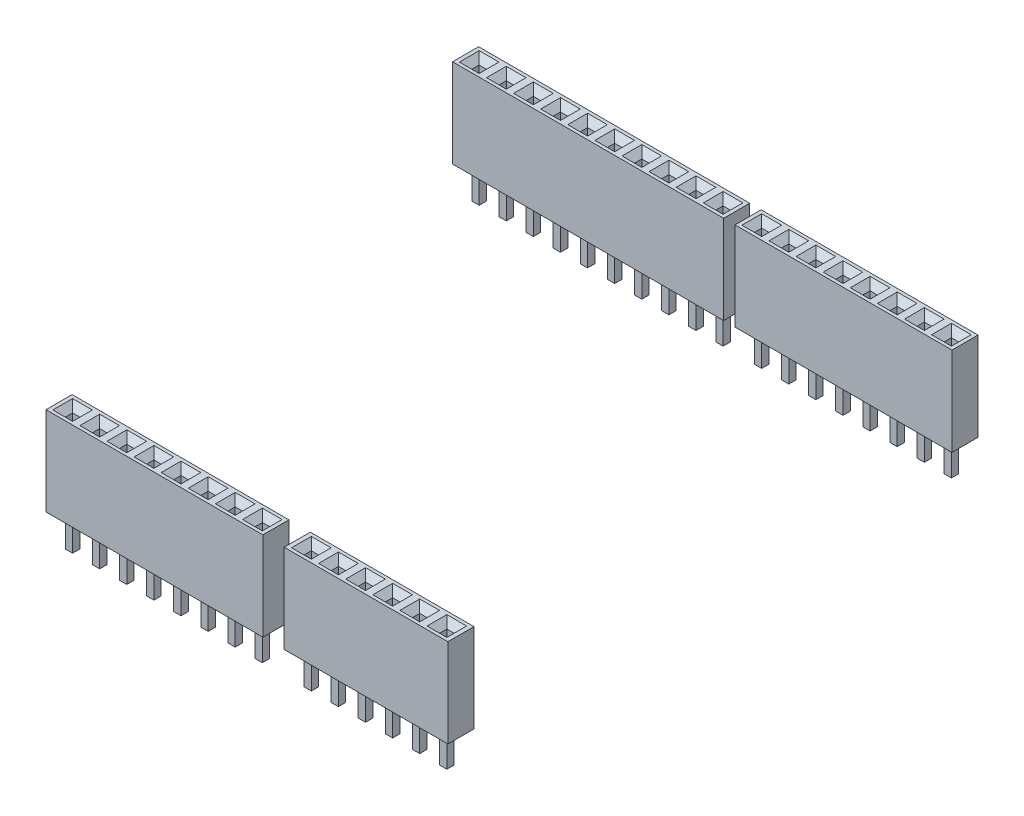
from build123d import *

# Parameters (mm, degrees)
ESQUISSE1_W             = 20.8
ESQUISSE1_H             = 2.5
BOSS_EXTRU_1_DEPTH      = 8.5
ESQUISSE1_W_2           = 15.7
BOSS_EXTRU_1_2_DEPTH    = 8.5
BOSS_EXTRU_1_3_DEPTH    = 8.5
ESQUISSE1_W_3           = 26
BOSS_EXTRU_1_4_DEPTH    = 8.5
ESQUISSE2_W             = 0.7
ESQUISSE2_H             = 0.7
BOSS_EXTRU_2_DEPTH      = 3.2
CHANFREIN1_SIZE         = 0.15
CHANFREIN2_SIZE         = 0.15
CHANFREIN3_SIZE         = 0.15
CHANFREIN4_SIZE         = 0.15
ESQUISSE3_W             = 0.7
ESQUISSE3_H             = 0.7
ENL_V_MAT_EXTRU_1_DEPTH = 7
CHANFREIN5_SIZE         = 0.6
CHANFREIN6_SIZE         = 0.6
CHANFREIN7_SIZE         = 0.6
CHANFREIN8_SIZE         = 0.6


with BuildPart() as part:
    # Esquisse1 → Boss.-Extru.1 (new body)
    with BuildSketch(Plane(origin=(0, 0, 0), x_dir=(1, 0, 0), z_dir=(0, 1, 0))):
        with Locations((10.4, 1.25)):
            Rectangle(ESQUISSE1_W, ESQUISSE1_H)
    extrude(amount=BOSS_EXTRU_1_DEPTH)



with BuildPart() as body_2:
    # Esquisse1 → Boss.-Extru.1 2 (new body)
    with BuildSketch(Plane(origin=(0, 0, 0), x_dir=(1, 0, 0), z_dir=(0, 1, 0))):
        with Locations((30.7, 1.25)):
            Rectangle(ESQUISSE1_W_2, ESQUISSE1_H)
    extrude(amount=BOSS_EXTRU_1_2_DEPTH)


with BuildPart() as body_3:
    # Esquisse1 → Boss.-Extru.1 3 (new body)
    with BuildSketch(Plane(origin=(0, 0, 0), x_dir=(1, 0, 0), z_dir=(0, 1, 0))):
        with Locations((28.1, 49.65)):
            Rectangle(ESQUISSE1_W, ESQUISSE1_H)
    extrude(amount=BOSS_EXTRU_1_3_DEPTH)


with BuildPart() as body_4:
    # Esquisse1 → Boss.-Extru.1 4 (new body)
    with BuildSketch(Plane(origin=(0, 0, 0), x_dir=(1, 0, 0), z_dir=(0, 1, 0))):
        with Locations((3.6, 49.65)):
            Rectangle(ESQUISSE1_W_3, ESQUISSE1_H)
    extrude(amount=BOSS_EXTRU_1_4_DEPTH)


with BuildPart() as part_1:
    add(part.part)

    add(body_2.part)  # Boss.-Extru.2 merges body 2

    add(body_3.part)  # Boss.-Extru.2 merges body 3

    add(body_4.part)  # Boss.-Extru.2 merges body 4
    # Esquisse2 → Boss.-Extru.2 (add)
    with BuildSketch(Plane.XZ):
        with Locations((1.3, -1.25)):
            Rectangle(ESQUISSE2_W, ESQUISSE2_H)
        with Locations((3.9, -1.25)):
            Rectangle(ESQUISSE2_W, ESQUISSE2_H)
        with Locations((6.5, -1.25)):
            Rectangle(ESQUISSE2_W, ESQUISSE2_H)
        with Locations((9.1, -1.25)):
            Rectangle(ESQUISSE2_W, ESQUISSE2_H)
        with Locations((11.7, -1.25)):
            Rectangle(ESQUISSE2_W, ESQUISSE2_H)
        with Locations((14.3, -1.25)):
            Rectangle(ESQUISSE2_W, ESQUISSE2_H)
        with Locations((16.9, -1.25)):
            Rectangle(ESQUISSE2_W, ESQUISSE2_H)
        with Locations((19.5, -1.25)):
            Rectangle(ESQUISSE2_W, ESQUISSE2_H)
        with Locations((24.2, -1.25)):
            Rectangle(ESQUISSE2_W, ESQUISSE2_H)
        with Locations((26.8, -1.25)):
            Rectangle(ESQUISSE2_W, ESQUISSE2_H)
        with Locations((29.4, -1.25)):
            Rectangle(ESQUISSE2_W, ESQUISSE2_H)
        with Locations((32, -1.25)):
            Rectangle(ESQUISSE2_W, ESQUISSE2_H)
        with Locations((34.6, -1.25)):
            Rectangle(ESQUISSE2_W, ESQUISSE2_H)
        with Locations((37.2, -1.25)):
            Rectangle(ESQUISSE2_W, ESQUISSE2_H)
        with Locations((-8.1, -49.65)):
            Rectangle(ESQUISSE2_W, ESQUISSE2_H)
        with Locations((-5.5, -49.65)):
            Rectangle(ESQUISSE2_W, ESQUISSE2_H)
        with Locations((-2.9, -49.65)):
            Rectangle(ESQUISSE2_W, ESQUISSE2_H)
        with Locations((-0.3, -49.65)):
            Rectangle(ESQUISSE2_W, ESQUISSE2_H)
        with Locations((2.3, -49.65)):
            Rectangle(ESQUISSE2_W, ESQUISSE2_H)
        with Locations((4.9, -49.65)):
            Rectangle(ESQUISSE2_W, ESQUISSE2_H)
        with Locations((7.5, -49.65)):
            Rectangle(ESQUISSE2_W, ESQUISSE2_H)
        with Locations((10.1, -49.65)):
            Rectangle(ESQUISSE2_W, ESQUISSE2_H)
        with Locations((12.7, -49.65)):
            Rectangle(ESQUISSE2_W, ESQUISSE2_H)
        with Locations((15.3, -49.65)):
            Rectangle(ESQUISSE2_W, ESQUISSE2_H)
        with Locations((19, -49.65)):
            Rectangle(ESQUISSE2_W, ESQUISSE2_H)
        with Locations((21.6, -49.65)):
            Rectangle(ESQUISSE2_W, ESQUISSE2_H)
        with Locations((24.2, -49.65)):
            Rectangle(ESQUISSE2_W, ESQUISSE2_H)
        with Locations((26.8, -49.65)):
            Rectangle(ESQUISSE2_W, ESQUISSE2_H)
        with Locations((29.4, -49.65)):
            Rectangle(ESQUISSE2_W, ESQUISSE2_H)
        with Locations((32, -49.65)):
            Rectangle(ESQUISSE2_W, ESQUISSE2_H)
        with Locations((34.6, -49.65)):
            Rectangle(ESQUISSE2_W, ESQUISSE2_H)
        with Locations((37.2, -49.65)):
            Rectangle(ESQUISSE2_W, ESQUISSE2_H)
    extrude(amount=BOSS_EXTRU_2_DEPTH)

    # Chanfrein1
    chanfrein1_edges = [part_1.edges().sort_by_distance(p)[0] for p in [
        (0.95, -3.2, -1.25),
        (1.3, -3.2, -1.6),
        (1.65, -3.2, -1.25),
        (1.3, -3.2, -0.9),
        (3.55, -3.2, -1.25),
        (3.9, -3.2, -1.6),
        (4.25, -3.2, -1.25),
        (3.9, -3.2, -0.9),
        (6.15, -3.2, -1.25),
        (6.5, -3.2, -1.6),
        (6.85, -3.2, -1.25),
        (6.5, -3.2, -0.9),
        (8.75, -3.2, -1.25),
        (9.1, -3.2, -1.6),
        (9.45, -3.2, -1.25),
        (9.1, -3.2, -0.9),
        (11.35, -3.2, -1.25),
        (11.7, -3.2, -1.6),
        (12.05, -3.2, -1.25),
        (11.7, -3.2, -0.9),
        (13.95, -3.2, -1.25),
        (14.3, -3.2, -1.6),
        (14.65, -3.2, -1.25),
        (14.3, -3.2, -0.9),
        (16.55, -3.2, -1.25),
        (16.9, -3.2, -1.6),
        (17.25, -3.2, -1.25),
        (16.9, -3.2, -0.9),
        (19.15, -3.2, -1.25),
        (19.5, -3.2, -1.6),
        (19.85, -3.2, -1.25),
        (19.5, -3.2, -0.9),
    ]]
    chamfer(chanfrein1_edges, length=CHANFREIN1_SIZE)

    # Chanfrein2
    chanfrein2_edges = [part_1.edges().sort_by_distance(p)[0] for p in [
        (26.45, -3.2, -1.25),
        (26.8, -3.2, -1.6),
        (27.15, -3.2, -1.25),
        (26.8, -3.2, -0.9),
        (23.85, -3.2, -1.25),
        (24.2, -3.2, -1.6),
        (24.55, -3.2, -1.25),
        (24.2, -3.2, -0.9),
        (29.05, -3.2, -1.25),
        (29.4, -3.2, -1.6),
        (29.75, -3.2, -1.25),
        (29.4, -3.2, -0.9),
        (31.65, -3.2, -1.25),
        (32, -3.2, -1.6),
        (32.35, -3.2, -1.25),
        (32, -3.2, -0.9),
        (34.25, -3.2, -1.25),
        (34.6, -3.2, -1.6),
        (34.95, -3.2, -1.25),
        (34.6, -3.2, -0.9),
        (36.85, -3.2, -1.25),
        (37.2, -3.2, -1.6),
        (37.55, -3.2, -1.25),
        (37.2, -3.2, -0.9),
    ]]
    chamfer(chanfrein2_edges, length=CHANFREIN2_SIZE)

    # Chanfrein3
    chanfrein3_edges = [part_1.edges().sort_by_distance(p)[0] for p in [
        (12.35, -3.2, -49.65),
        (12.7, -3.2, -50),
        (13.05, -3.2, -49.65),
        (12.7, -3.2, -49.3),
        (14.95, -3.2, -49.65),
        (15.3, -3.2, -50),
        (15.65, -3.2, -49.65),
        (15.3, -3.2, -49.3),
        (-8.45, -3.2, -49.65),
        (-8.1, -3.2, -50),
        (-7.75, -3.2, -49.65),
        (-8.1, -3.2, -49.3),
        (-5.85, -3.2, -49.65),
        (-5.5, -3.2, -50),
        (-5.15, -3.2, -49.65),
        (-5.5, -3.2, -49.3),
        (-3.25, -3.2, -49.65),
        (-2.9, -3.2, -50),
        (-2.55, -3.2, -49.65),
        (-2.9, -3.2, -49.3),
        (-0.65, -3.2, -49.65),
        (-0.3, -3.2, -50),
        (0.05, -3.2, -49.65),
        (-0.3, -3.2, -49.3),
        (1.95, -3.2, -49.65),
        (2.3, -3.2, -50),
        (2.65, -3.2, -49.65),
        (2.3, -3.2, -49.3),
        (4.55, -3.2, -49.65),
        (4.9, -3.2, -50),
        (5.25, -3.2, -49.65),
        (4.9, -3.2, -49.3),
        (7.15, -3.2, -49.65),
        (7.5, -3.2, -50),
        (7.85, -3.2, -49.65),
        (7.5, -3.2, -49.3),
        (9.75, -3.2, -49.65),
        (10.1, -3.2, -50),
        (10.45, -3.2, -49.65),
        (10.1, -3.2, -49.3),
    ]]
    chamfer(chanfrein3_edges, length=CHANFREIN3_SIZE)

    # Chanfrein4
    chanfrein4_edges = [part_1.edges().sort_by_distance(p)[0] for p in [
        (18.65, -3.2, -49.65),
        (19, -3.2, -50),
        (19.35, -3.2, -49.65),
        (19, -3.2, -49.3),
        (21.25, -3.2, -49.65),
        (21.6, -3.2, -50),
        (21.95, -3.2, -49.65),
        (21.6, -3.2, -49.3),
        (23.85, -3.2, -49.65),
        (24.2, -3.2, -50),
        (24.55, -3.2, -49.65),
        (24.2, -3.2, -49.3),
        (26.45, -3.2, -49.65),
        (26.8, -3.2, -50),
        (27.15, -3.2, -49.65),
        (26.8, -3.2, -49.3),
        (29.05, -3.2, -49.65),
        (29.4, -3.2, -50),
        (29.75, -3.2, -49.65),
        (29.4, -3.2, -49.3),
        (31.65, -3.2, -49.65),
        (32, -3.2, -50),
        (32.35, -3.2, -49.65),
        (32, -3.2, -49.3),
        (34.25, -3.2, -49.65),
        (34.6, -3.2, -50),
        (34.95, -3.2, -49.65),
        (34.6, -3.2, -49.3),
        (36.85, -3.2, -49.65),
        (37.2, -3.2, -50),
        (37.55, -3.2, -49.65),
        (37.2, -3.2, -49.3),
    ]]
    chamfer(chanfrein4_edges, length=CHANFREIN4_SIZE)

    # Esquisse3 → Enlèv. mat.-Extru.1 (cut)
    with BuildSketch(Plane(origin=(0, 8.5, 0), x_dir=(1, 0, 0), z_dir=(0, 1, 0))):
        with Locations((24.2, 49.65)):
            Rectangle(ESQUISSE3_W, ESQUISSE3_H)
        with Locations((21.6, 49.65)):
            Rectangle(ESQUISSE3_W, ESQUISSE3_H)
        with Locations((29.4, 49.65)):
            Rectangle(ESQUISSE3_W, ESQUISSE3_H)
        with Locations((26.8, 49.65)):
            Rectangle(ESQUISSE3_W, ESQUISSE3_H)
        with Locations((34.6, 49.65)):
            Rectangle(ESQUISSE3_W, ESQUISSE3_H)
        with Locations((32, 49.65)):
            Rectangle(ESQUISSE3_W, ESQUISSE3_H)
        with Locations((3.9, 1.25)):
            Rectangle(ESQUISSE3_W, ESQUISSE3_H)
        with Locations((1.3, 1.25)):
            Rectangle(ESQUISSE3_W, ESQUISSE3_H)
        with Locations((37.2, 49.65)):
            Rectangle(ESQUISSE3_W, ESQUISSE3_H)
        with Locations((6.5, 1.25)):
            Rectangle(ESQUISSE3_W, ESQUISSE3_H)
        with Locations((11.7, 1.25)):
            Rectangle(ESQUISSE3_W, ESQUISSE3_H)
        with Locations((9.1, 1.25)):
            Rectangle(ESQUISSE3_W, ESQUISSE3_H)
        with Locations((16.9, 1.25)):
            Rectangle(ESQUISSE3_W, ESQUISSE3_H)
        with Locations((14.3, 1.25)):
            Rectangle(ESQUISSE3_W, ESQUISSE3_H)
        with Locations((19.5, 1.25)):
            Rectangle(ESQUISSE3_W, ESQUISSE3_H)
        with Locations((26.8, 1.25)):
            Rectangle(ESQUISSE3_W, ESQUISSE3_H)
        with Locations((24.2, 1.25)):
            Rectangle(ESQUISSE3_W, ESQUISSE3_H)
        with Locations((29.4, 1.25)):
            Rectangle(ESQUISSE3_W, ESQUISSE3_H)
        with Locations((34.6, 1.25)):
            Rectangle(ESQUISSE3_W, ESQUISSE3_H)
        with Locations((32, 1.25)):
            Rectangle(ESQUISSE3_W, ESQUISSE3_H)
        with Locations((37.2, 1.25)):
            Rectangle(ESQUISSE3_W, ESQUISSE3_H)
        with Locations((-5.5, 49.65)):
            Rectangle(ESQUISSE3_W, ESQUISSE3_H)
        with Locations((-8.1, 49.65)):
            Rectangle(ESQUISSE3_W, ESQUISSE3_H)
        with Locations((-0.3, 49.65)):
            Rectangle(ESQUISSE3_W, ESQUISSE3_H)
        with Locations((-2.9, 49.65)):
            Rectangle(ESQUISSE3_W, ESQUISSE3_H)
        with Locations((4.9, 49.65)):
            Rectangle(ESQUISSE3_W, ESQUISSE3_H)
        with Locations((2.3, 49.65)):
            Rectangle(ESQUISSE3_W, ESQUISSE3_H)
        with Locations((10.1, 49.65)):
            Rectangle(ESQUISSE3_W, ESQUISSE3_H)
        with Locations((7.5, 49.65)):
            Rectangle(ESQUISSE3_W, ESQUISSE3_H)
        with Locations((15.3, 49.65)):
            Rectangle(ESQUISSE3_W, ESQUISSE3_H)
        with Locations((12.7, 49.65)):
            Rectangle(ESQUISSE3_W, ESQUISSE3_H)
        with Locations((19, 49.65)):
            Rectangle(ESQUISSE3_W, ESQUISSE3_H)
    extrude(amount=-ENL_V_MAT_EXTRU_1_DEPTH, mode=Mode.SUBTRACT)

    # Chanfrein5
    chanfrein5_edges = [part_1.edges().sort_by_distance(p)[0] for p in [
        (-5.85, 8.5, -49.65),
        (-5.5, 8.5, -49.3),
        (-5.15, 8.5, -49.65),
        (-5.5, 8.5, -50),
        (-8.45, 8.5, -49.65),
        (-8.1, 8.5, -49.3),
        (-7.75, 8.5, -49.65),
        (-8.1, 8.5, -50),
        (-0.65, 8.5, -49.65),
        (-0.3, 8.5, -49.3),
        (0.05, 8.5, -49.65),
        (-0.3, 8.5, -50),
        (-3.25, 8.5, -49.65),
        (-2.9, 8.5, -49.3),
        (-2.55, 8.5, -49.65),
        (-2.9, 8.5, -50),
        (4.55, 8.5, -49.65),
        (4.9, 8.5, -49.3),
        (5.25, 8.5, -49.65),
        (4.9, 8.5, -50),
        (1.95, 8.5, -49.65),
        (2.3, 8.5, -49.3),
        (2.65, 8.5, -49.65),
        (2.3, 8.5, -50),
        (9.75, 8.5, -49.65),
        (10.1, 8.5, -49.3),
        (10.45, 8.5, -49.65),
        (10.1, 8.5, -50),
        (7.15, 8.5, -49.65),
        (7.5, 8.5, -49.3),
        (7.85, 8.5, -49.65),
        (7.5, 8.5, -50),
        (14.95, 8.5, -49.65),
        (15.3, 8.5, -49.3),
        (15.65, 8.5, -49.65),
        (15.3, 8.5, -50),
        (12.35, 8.5, -49.65),
        (12.7, 8.5, -49.3),
        (13.05, 8.5, -49.65),
        (12.7, 8.5, -50),
    ]]
    chamfer(chanfrein5_edges, length=CHANFREIN5_SIZE)

    # Chanfrein6
    chanfrein6_edges = [part_1.edges().sort_by_distance(p)[0] for p in [
        (23.85, 8.5, -49.65),
        (24.2, 8.5, -49.3),
        (24.55, 8.5, -49.65),
        (24.2, 8.5, -50),
        (21.25, 8.5, -49.65),
        (21.6, 8.5, -49.3),
        (21.95, 8.5, -49.65),
        (21.6, 8.5, -50),
        (29.05, 8.5, -49.65),
        (29.4, 8.5, -49.3),
        (29.75, 8.5, -49.65),
        (29.4, 8.5, -50),
        (26.45, 8.5, -49.65),
        (26.8, 8.5, -49.3),
        (27.15, 8.5, -49.65),
        (26.8, 8.5, -50),
        (34.25, 8.5, -49.65),
        (34.6, 8.5, -49.3),
        (34.95, 8.5, -49.65),
        (34.6, 8.5, -50),
        (31.65, 8.5, -49.65),
        (32, 8.5, -49.3),
        (32.35, 8.5, -49.65),
        (32, 8.5, -50),
        (36.85, 8.5, -49.65),
        (37.2, 8.5, -49.3),
        (37.55, 8.5, -49.65),
        (37.2, 8.5, -50),
        (18.65, 8.5, -49.65),
        (19, 8.5, -49.3),
        (19.35, 8.5, -49.65),
        (19, 8.5, -50),
    ]]
    chamfer(chanfrein6_edges, length=CHANFREIN6_SIZE)

    # Chanfrein7
    chanfrein7_edges = [part_1.edges().sort_by_distance(p)[0] for p in [
        (26.45, 8.5, -1.25),
        (26.8, 8.5, -0.9),
        (27.15, 8.5, -1.25),
        (26.8, 8.5, -1.6),
        (23.85, 8.5, -1.25),
        (24.2, 8.5, -0.9),
        (24.55, 8.5, -1.25),
        (24.2, 8.5, -1.6),
        (29.05, 8.5, -1.25),
        (29.4, 8.5, -0.9),
        (29.75, 8.5, -1.25),
        (29.4, 8.5, -1.6),
        (34.25, 8.5, -1.25),
        (34.6, 8.5, -0.9),
        (34.95, 8.5, -1.25),
        (34.6, 8.5, -1.6),
        (31.65, 8.5, -1.25),
        (32, 8.5, -0.9),
        (32.35, 8.5, -1.25),
        (32, 8.5, -1.6),
        (36.85, 8.5, -1.25),
        (37.2, 8.5, -0.9),
        (37.55, 8.5, -1.25),
        (37.2, 8.5, -1.6),
    ]]
    chamfer(chanfrein7_edges, length=CHANFREIN7_SIZE)

    # Chanfrein8
    chanfrein8_edges = [part_1.edges().sort_by_distance(p)[0] for p in [
        (3.55, 8.5, -1.25),
        (3.9, 8.5, -0.9),
        (4.25, 8.5, -1.25),
        (3.9, 8.5, -1.6),
        (0.95, 8.5, -1.25),
        (1.3, 8.5, -0.9),
        (1.65, 8.5, -1.25),
        (1.3, 8.5, -1.6),
        (6.15, 8.5, -1.25),
        (6.5, 8.5, -0.9),
        (6.85, 8.5, -1.25),
        (6.5, 8.5, -1.6),
        (11.35, 8.5, -1.25),
        (11.7, 8.5, -0.9),
        (12.05, 8.5, -1.25),
        (11.7, 8.5, -1.6),
        (8.75, 8.5, -1.25),
        (9.1, 8.5, -0.9),
        (9.45, 8.5, -1.25),
        (9.1, 8.5, -1.6),
        (16.55, 8.5, -1.25),
        (16.9, 8.5, -0.9),
        (17.25, 8.5, -1.25),
        (16.9, 8.5, -1.6),
        (13.95, 8.5, -1.25),
        (14.3, 8.5, -0.9),
        (14.65, 8.5, -1.25),
        (14.3, 8.5, -1.6),
        (19.15, 8.5, -1.25),
        (19.5, 8.5, -0.9),
        (19.85, 8.5, -1.25),
        (19.5, 8.5, -1.6),
    ]]
    chamfer(chanfrein8_edges, length=CHANFREIN8_SIZE)


solid = part_1.part
